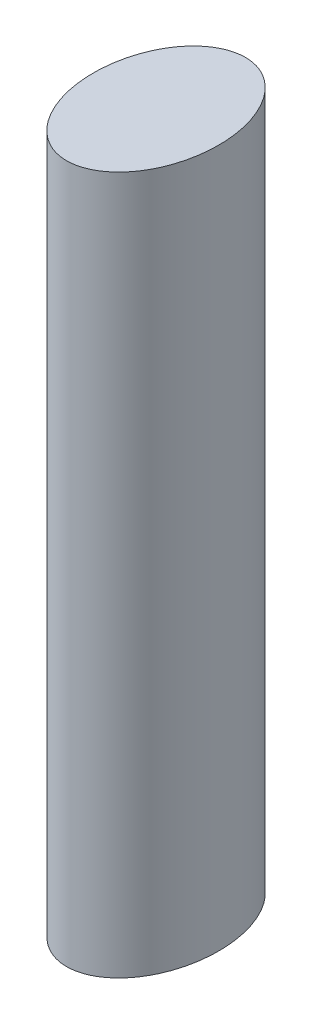
from build123d import *

# Parameters (mm, degrees)
SKETCH2_RX          = 25
SKETCH2_RY          = 17.5
BOSS_EXTRUDE1_DEPTH = 195


with BuildPart() as part:
    # Sketch2 → Boss-Extrude1 (new body)
    with BuildSketch(Plane(origin=(0, 0, 0), x_dir=(1, 0, 0), z_dir=(0, 1, 0))):
        with Locations(Location((0, 0), (0, 0, 90))):
            Ellipse(SKETCH2_RX, SKETCH2_RY)
    extrude(amount=BOSS_EXTRUDE1_DEPTH)


solid = part.part
